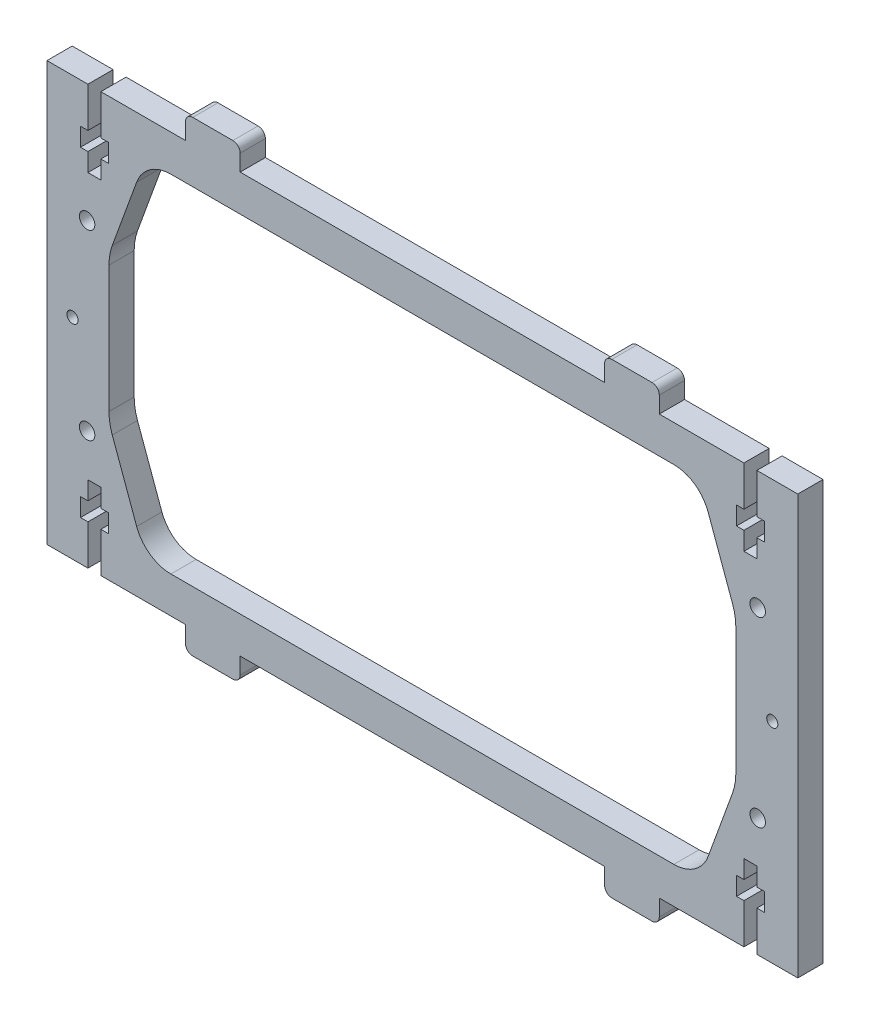
from build123d import *

# Parameters (mm, degrees)
SKETCH1_R           = 2.125
SKETCH1_R_2         = 1.524
BOSS_EXTRUDE1_DEPTH = 6.92


with BuildPart() as part:
    # Sketch1 → Boss-Extrude1 (new body)
    with BuildSketch(Plane.XY):
        with BuildLine():
            Line((192.041969112, 105.207722008), (192.041969112, 110.207722008))
            Line((192.041969112, 110.207722008), (194.076969112, 110.207722008))
            Line((194.076969112, 110.207722008), (194.076969112, 121.207722008))
            Line((194.076969112, 121.207722008), (170.851969112, 121.207722008))
            Line((170.851969112, 121.207722008), (170.851969112, 125.707722008))
            ThreePointArc((170.851969112, 125.707722008), (170.266182674, 127.12193557), (168.851969112, 127.707722008))
            Line((168.851969112, 127.707722008), (157.851969112, 127.707722008))
            ThreePointArc((157.851969112, 127.707722008), (156.43775555, 127.12193557), (155.851969112, 125.707722008))
            Line((155.851969112, 125.707722008), (155.851969112, 121.207722008))
            Line((155.851969112, 121.207722008), (55.851969112, 121.207722008))
            Line((55.851969112, 121.207722008), (55.851969112, 125.707722008))
            ThreePointArc((55.851969112, 125.707722008), (55.266182674, 127.12193557), (53.851969112, 127.707722008))
            Line((53.851969112, 127.707722008), (42.851969112, 127.707722008))
            ThreePointArc((42.851969112, 127.707722008), (41.43775555, 127.12193557), (40.851969112, 125.707722008))
            Line((40.851969112, 125.707722008), (40.851969112, 121.207722008))
            Line((40.851969112, 121.207722008), (17.626969112, 121.207722008))
            Line((17.626969112, 121.207722008), (17.626969112, 110.207722008))
            Line((17.626969112, 110.207722008), (19.661969112, 110.207722008))
            Line((19.661969112, 110.207722008), (19.661969112, 105.207722008))
            Line((19.661969112, 105.207722008), (17.626969112, 105.207722008))
            Line((17.626969112, 105.207722008), (17.626969112, 100.207722008))
            Line((17.626969112, 100.207722008), (14.076969112, 100.207722008))
            Line((14.076969112, 100.207722008), (14.076969112, 105.207722008))
            Line((14.076969112, 105.207722008), (12.041969112, 105.207722008))
            Line((12.041969112, 105.207722008), (12.041969112, 110.207722008))
            Line((12.041969112, 110.207722008), (14.076969112, 110.207722008))
            Line((14.076969112, 110.207722008), (14.076969112, 121.207722008))
            Line((14.076969112, 121.207722008), (2.851969112, 121.207722008))
            Line((2.851969112, 121.207722008), (2.851969112, 6.207722008))
            Line((2.851969112, 6.207722008), (14.076969112, 6.207722008))
            Line((14.076969112, 6.207722008), (14.076969112, 17.207722008))
            Line((14.076969112, 17.207722008), (12.041969112, 17.207722008))
            Line((12.041969112, 17.207722008), (12.041969112, 22.207722008))
            Line((12.041969112, 22.207722008), (14.076969112, 22.207722008))
            Line((14.076969112, 22.207722008), (14.076969112, 27.207722008))
            Line((14.076969112, 27.207722008), (17.626969112, 27.207722008))
            Line((17.626969112, 27.207722008), (17.626969112, 22.207722008))
            Line((17.626969112, 22.207722008), (19.661969112, 22.207722008))
            Line((19.661969112, 22.207722008), (19.661969112, 17.207722008))
            Line((19.661969112, 17.207722008), (17.626969112, 17.207722008))
            Line((17.626969112, 17.207722008), (17.626969112, 6.207722008))
            Line((17.626969112, 6.207722008), (40.851969112, 6.207722008))
            Line((40.851969112, 6.207722008), (40.851969112, 1.707722008))
            ThreePointArc((40.851969112, 1.707722008), (41.43775555, 0.293508445), (42.851969112, -0.292277992))
            Line((42.851969112, -0.292277992), (53.851969112, -0.292277992))
            ThreePointArc((53.851969112, -0.292277992), (55.266182674, 0.293508445), (55.851969112, 1.707722008))
            Line((55.851969112, 1.707722008), (55.851969112, 6.207722008))
            Line((55.851969112, 6.207722008), (155.851969112, 6.207722008))
            Line((155.851969112, 6.207722008), (155.851969112, 1.707722008))
            ThreePointArc((155.851969112, 1.707722008), (156.43775555, 0.293508445), (157.851969112, -0.292277992))
            Line((157.851969112, -0.292277992), (168.851969112, -0.292277992))
            ThreePointArc((168.851969112, -0.292277992), (170.266182674, 0.293508445), (170.851969112, 1.707722008))
            Line((170.851969112, 1.707722008), (170.851969112, 6.207722008))
            Line((170.851969112, 6.207722008), (194.076969112, 6.207722008))
            Line((194.076969112, 6.207722008), (194.076969112, 17.207722008))
            Line((194.076969112, 17.207722008), (192.041969112, 17.207722008))
            Line((192.041969112, 17.207722008), (192.041969112, 22.207722008))
            Line((192.041969112, 22.207722008), (194.076969112, 22.207722008))
            Line((194.076969112, 22.207722008), (194.076969112, 27.207722008))
            Line((194.076969112, 27.207722008), (197.626969112, 27.207722008))
            Line((197.626969112, 27.207722008), (197.626969112, 22.207722008))
            Line((197.626969112, 22.207722008), (199.661969112, 22.207722008))
            Line((199.661969112, 22.207722008), (199.661969112, 17.207722008))
            Line((199.661969112, 17.207722008), (197.626969112, 17.207722008))
            Line((197.626969112, 17.207722008), (197.626969112, 6.207722008))
            Line((197.626969112, 6.207722008), (208.851969112, 6.207722008))
            Line((208.851969112, 6.207722008), (208.851969112, 121.207722008))
            Line((208.851969112, 121.207722008), (197.626969112, 121.207722008))
            Line((197.626969112, 121.207722008), (197.626969112, 110.207722008))
            Line((197.626969112, 110.207722008), (199.661969112, 110.207722008))
            Line((199.661969112, 110.207722008), (199.661969112, 105.207722008))
            Line((199.661969112, 105.207722008), (197.626969112, 105.207722008))
            Line((197.626969112, 105.207722008), (197.626969112, 100.207722008))
            Line((197.626969112, 100.207722008), (194.076969112, 100.207722008))
            Line((194.076969112, 100.207722008), (194.076969112, 105.207722008))
            Line((194.076969112, 105.207722008), (192.041969112, 105.207722008))
        make_face()
        with Locations((13.851969112, 38.707722008)):
            Circle(SKETCH1_R, mode=Mode.SUBTRACT)
        with Locations((197.851969112, 88.707722008)):
            Circle(SKETCH1_R, mode=Mode.SUBTRACT)
        with Locations((13.851969112, 88.707722008)):
            Circle(SKETCH1_R, mode=Mode.SUBTRACT)
        with Locations((197.851969112, 38.707722008)):
            Circle(SKETCH1_R, mode=Mode.SUBTRACT)
        with Locations((9.851969112, 63.707722008)):
            Circle(SKETCH1_R_2, mode=Mode.SUBTRACT)
        with Locations((201.851969112, 63.707722008)):
            Circle(SKETCH1_R_2, mode=Mode.SUBTRACT)
        with BuildLine():
            Line((19.851969112, 81.093745168), (19.851969112, 46.321698847))
            ThreePointArc((19.851969112, 46.321698847), (20.079852817, 43.716976182), (20.7565798, 41.191396698))
            Line((20.7565798, 41.191396698), (27.455042904, 22.787520574))
            ThreePointArc((27.455042904, 22.787520574), (31.116204748, 18.016201565), (36.851969112, 16.207722008))
            Line((36.851969112, 16.207722008), (174.851969112, 16.207722008))
            ThreePointArc((174.851969112, 16.207722008), (180.587733475, 18.016201565), (184.24889532, 22.787520574))
            Line((184.24889532, 22.787520574), (190.947358424, 41.191396698))
            ThreePointArc((190.947358424, 41.191396698), (191.624085407, 43.716976182), (191.851969112, 46.321698847))
            Line((191.851969112, 46.321698847), (191.851969112, 81.093745168))
            ThreePointArc((191.851969112, 81.093745168), (191.624085407, 83.698467833), (190.947358424, 86.224047318))
            Line((190.947358424, 86.224047318), (184.24889532, 104.627923441))
            ThreePointArc((184.24889532, 104.627923441), (180.587733475, 109.399242451), (174.851969112, 111.207722008))
            Line((174.851969112, 111.207722008), (36.851969112, 111.207722008))
            ThreePointArc((36.851969112, 111.207722008), (31.116204748, 109.399242451), (27.455042904, 104.627923441))
            Line((27.455042904, 104.627923441), (20.7565798, 86.224047318))
            ThreePointArc((20.7565798, 86.224047318), (20.079852817, 83.698467833), (19.851969112, 81.093745168))
        make_face(mode=Mode.SUBTRACT)
    extrude(amount=BOSS_EXTRUDE1_DEPTH)


solid = part.part
